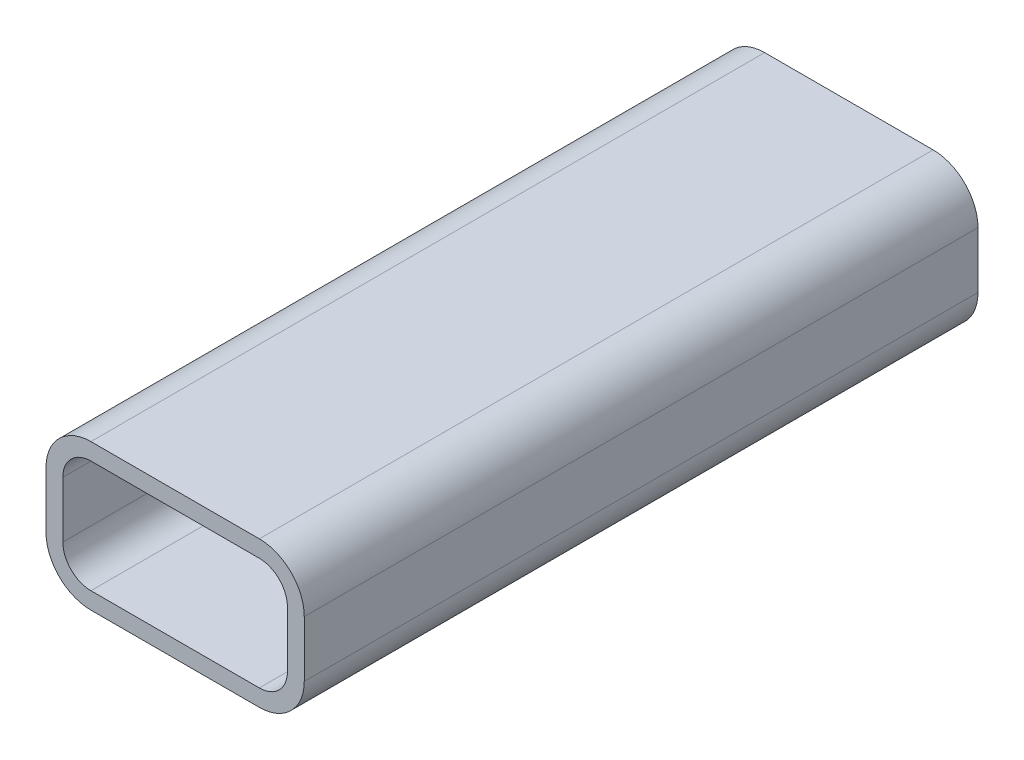
from build123d import *

# Parameters (mm, degrees)
EXTRUDE_THIN1_DEPTH = 60


with BuildPart() as part:
    # Sketch1 → Extrude-Thin1 (new body, symmetric)
    with BuildSketch(Plane.XY):
        with BuildLine():
            Line((-15, 13), (15, 13))
            ThreePointArc((15, 13), (20.656854249, 10.656854249), (23, 5))
            Line((23, 5), (23, -5))
            ThreePointArc((23, -5), (20.656854249, -10.656854249), (15, -13))
            Line((15, -13), (-15, -13))
            ThreePointArc((-15, -13), (-20.656854249, -10.656854249), (-23, -5))
            Line((-23, -5), (-23, 5))
            ThreePointArc((-23, 5), (-20.656854249, 10.656854249), (-15, 13))
        make_face()
        with BuildLine():
            Line((-15, 10), (15, 10))
            ThreePointArc((15, 10), (18.535533906, 8.535533906), (20, 5))
            Line((20, 5), (20, -5))
            ThreePointArc((20, -5), (18.535533906, -8.535533906), (15, -10))
            Line((15, -10), (-15, -10))
            ThreePointArc((-15, -10), (-18.535533906, -8.535533906), (-20, -5))
            Line((-20, -5), (-20, 5))
            ThreePointArc((-20, 5), (-18.535533906, 8.535533906), (-15, 10))
        make_face(mode=Mode.SUBTRACT)
    extrude(amount=EXTRUDE_THIN1_DEPTH, both=True)


solid = part.part
